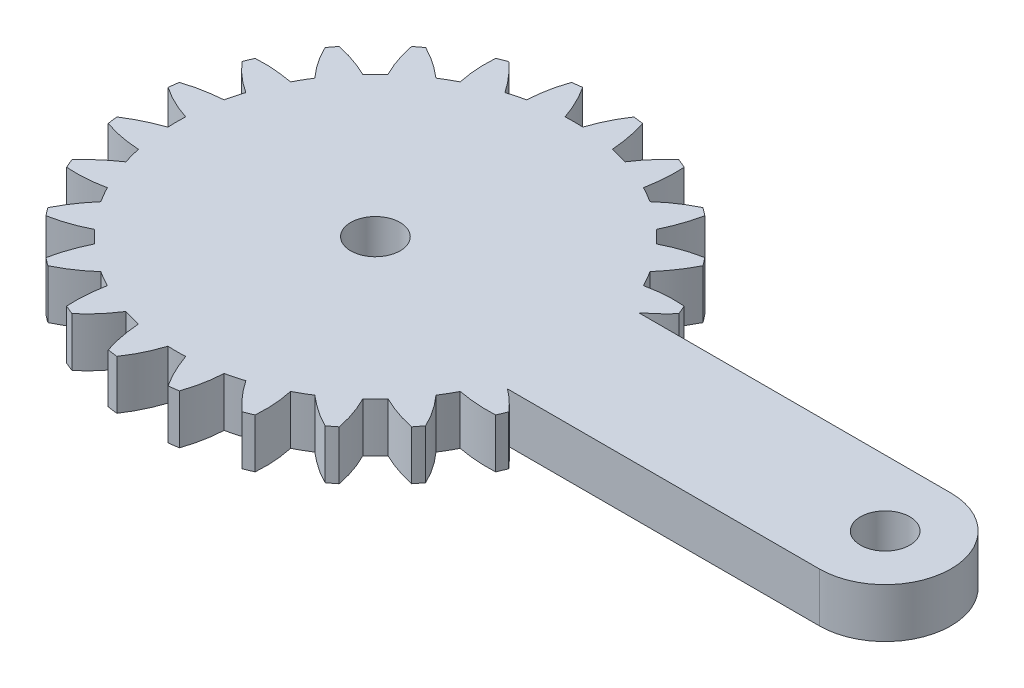
from build123d import *

# Parameters (mm, degrees)
SKETCH2_R           = 1.5
BOSS_EXTRUDE1_DEPTH = 3


with BuildPart() as part:
    # Sketch2 → Boss-Extrude1 (new body)
    with BuildSketch(Plane(origin=(0, 0, 0), x_dir=(1, 0, 0), z_dir=(0, 1, 0))):
        with BuildLine():
            Line((31, 4.000000001), (12.012859152, 4.000000001))
            add(Edge.make_bspline(
                [(13.278985865, 5.170206419), (12.8954662, 4.733530556), (12.462190225, 4.344528056), (12.012859152, 4.000000001)],
                knots=[0.154712813, 0.154712813, 0.154712813, 0.154712813, 0.777489596, 0.777489596, 0.777489596, 0.777489596], degree=3))
            ThreePointArc((13.278985865, 5.170206419), (13.165283338, 5.453238911), (13.045548971, 5.733772933))
            add(Edge.make_bspline(
                [(10.729735914, 5.571433139), (11.468148216, 5.731782959), (12.25282672, 5.797378255), (13.045548971, 5.733772933)],
                knots=[0, 0, 0, 0, 0.84522739, 0.84522739, 0.84522739, 0.84522739], degree=3))
            ThreePointArc((10.729735914, 5.571433139), (10.602635836, 5.809665509), (10.470247132, 6.045))
            ThreePointArc((10.470247132, 6.045), (10.332600838, 6.277376835), (10.189798038, 6.506620931))
            add(Edge.make_bspline(
                [(11.488367505, 8.430890348), (11.138958904, 7.723663869), (10.678280228, 7.077546079), (10.189798038, 6.506620931)],
                knots=[0.154712813, 0.154712813, 0.154712813, 0.154712813, 1, 1, 1, 1], degree=3))
            ThreePointArc((11.488367505, 8.430890348), (11.305285099, 8.674850363), (11.117023034, 8.914835886))
            add(Edge.make_bspline(
                [(8.922136024, 8.158651162), (9.593885949, 8.504652361), (10.334849869, 8.771102293), (11.117023034, 8.914835886)],
                knots=[0, 0, 0, 0, 0.84522739, 0.84522739, 0.84522739, 0.84522739], degree=3))
            ThreePointArc((8.922136024, 8.158651162), (8.737707702, 8.35587004), (8.548920985, 8.548920985))
            ThreePointArc((8.548920985, 8.548920985), (8.355821324, 8.737754288), (8.158551674, 8.922226997))
            add(Edge.make_bspline(
                [(8.914835886, 11.117023034), (8.760376776, 10.343461111), (8.482622935, 9.600126837), (8.158551674, 8.922226997)],
                knots=[0.154712813, 0.154712813, 0.154712813, 0.154712813, 1, 1, 1, 1], degree=3))
            ThreePointArc((8.914835886, 11.117023034), (8.674850363, 11.305285099), (8.430890348, 11.488367505))
            add(Edge.make_bspline(
                [(6.506507308, 10.189870591), (7.065816209, 10.697943759), (7.71257008, 11.147090204), (8.430890348, 11.488367505)],
                knots=[0, 0, 0, 0, 0.84522739, 0.84522739, 0.84522739, 0.84522739], degree=3))
            ThreePointArc((6.506507308, 10.189870591), (6.277319227, 10.332635836), (6.045, 10.470247132))
            ThreePointArc((6.045, 10.470247132), (5.809606396, 10.602668227), (5.571313495, 10.729798038))
            add(Edge.make_bspline(
                [(5.733772933, 13.045548971), (5.784789448, 12.258368573), (5.708888907, 11.468474815), (5.571313495, 10.729798038)],
                knots=[0.154712813, 0.154712813, 0.154712813, 0.154712813, 1, 1, 1, 1], degree=3))
            ThreePointArc((5.733772933, 13.045548971), (5.453238911, 13.165283338), (5.170206419, 13.278985865))
            add(Edge.make_bspline(
                [(3.647470872, 11.526667178), (4.056222772, 12.16218797), (4.564691385, 12.76342234), (5.170206419, 13.278985865)],
                knots=[0, 0, 0, 0, 0.84522739, 0.84522739, 0.84522739, 0.84522739], degree=3))
            ThreePointArc((3.647470872, 11.526667178), (3.389141821, 11.605249576), (3.129122255, 11.67804324))
            ThreePointArc((3.129122255, 11.67804324), (2.867476392, 11.745027848), (2.604399509, 11.806151075))
            add(Edge.make_bspline(
                [(2.161962831, 14.085042304), (2.414978279, 13.337888473), (2.546103534, 12.555265188), (2.604399509, 11.806151075)],
                knots=[0.154712813, 0.154712813, 0.154712813, 0.154712813, 1, 1, 1, 1], degree=3))
            ThreePointArc((2.161962831, 14.085042304), (1.859998239, 14.128089275), (1.557181466, 14.164663282))
            add(Edge.make_bspline(
                [(0.539865323, 12.077940447), (0.770204456, 12.797599169), (1.105736515, 13.509948335), (1.557181466, 14.164663282)],
                knots=[0, 0, 0, 0, 0.84522739, 0.84522739, 0.84522739, 0.84522739], degree=3))
            ThreePointArc((0.539865323, 12.077940447), (0.27, 12.086984736), (0, 12.09))
            ThreePointArc((0, 12.09), (-0.270067389, 12.08698323), (-0.54, 12.077934426))
            add(Edge.make_bspline(
                [(-1.557181466, 14.164663282), (-1.119409669, 13.508453317), (-0.790194587, 12.786434986), (-0.54, 12.077934426)],
                knots=[0.154712813, 0.154712813, 0.154712813, 0.154712813, 1, 1, 1, 1], degree=3))
            ThreePointArc((-1.557181466, 14.164663282), (-1.859998239, 14.128089275), (-2.161962831, 14.085042304))
            add(Edge.make_bspline(
                [(-2.604531155, 11.806122033), (-2.568302021, 12.560875133), (-2.42857247, 13.335793678), (-2.161962831, 14.085042304)],
                knots=[0, 0, 0, 0, 0.84522739, 0.84522739, 0.84522739, 0.84522739], degree=3))
            ThreePointArc((-2.604531155, 11.806122033), (-2.867541874, 11.74501186), (-3.129122255, 11.67804324))
            ThreePointArc((-3.129122255, 11.67804324), (-3.389206524, 11.60523068), (-3.647599401, 11.526626506))
            add(Edge.make_bspline(
                [(-5.170206419, 13.278985865), (-4.577511698, 12.75843939), (-4.072642252, 12.146230371), (-3.647599401, 11.526626506)],
                knots=[0.154712813, 0.154712813, 0.154712813, 0.154712813, 1, 1, 1, 1], degree=3))
            ThreePointArc((-5.170206419, 13.278985865), (-5.453238911, 13.165283338), (-5.733772933, 13.045548971))
            add(Edge.make_bspline(
                [(-5.571433139, 10.729735914), (-5.731782959, 11.468148216), (-5.797378255, 12.25282672), (-5.733772933, 13.045548971)],
                knots=[0, 0, 0, 0, 0.84522739, 0.84522739, 0.84522739, 0.84522739], degree=3))
            ThreePointArc((-5.571433139, 10.729735914), (-5.809665509, 10.602635836), (-6.045, 10.470247132))
            ThreePointArc((-6.045, 10.470247132), (-6.277376835, 10.332600838), (-6.506620931, 10.189798038))
            add(Edge.make_bspline(
                [(-8.430890348, 11.488367505), (-7.723663869, 11.138958904), (-7.077546079, 10.678280228), (-6.506620931, 10.189798038)],
                knots=[0.154712813, 0.154712813, 0.154712813, 0.154712813, 1, 1, 1, 1], degree=3))
            ThreePointArc((-8.430890348, 11.488367505), (-8.674850363, 11.305285099), (-8.914835886, 11.117023034))
            add(Edge.make_bspline(
                [(-8.158651162, 8.922136024), (-8.504652361, 9.593885949), (-8.771102293, 10.334849869), (-8.914835886, 11.117023034)],
                knots=[0, 0, 0, 0, 0.84522739, 0.84522739, 0.84522739, 0.84522739], degree=3))
            ThreePointArc((-8.158651162, 8.922136024), (-8.35587004, 8.737707702), (-8.548920985, 8.548920985))
            ThreePointArc((-8.548920985, 8.548920985), (-8.737754288, 8.355821324), (-8.922226997, 8.158551674))
            add(Edge.make_bspline(
                [(-11.117023034, 8.914835886), (-10.343461111, 8.760376776), (-9.600126837, 8.482622935), (-8.922226997, 8.158551674)],
                knots=[0.154712813, 0.154712813, 0.154712813, 0.154712813, 1, 1, 1, 1], degree=3))
            ThreePointArc((-11.117023034, 8.914835886), (-11.305285099, 8.674850363), (-11.488367505, 8.430890348))
            add(Edge.make_bspline(
                [(-10.189870591, 6.506507308), (-10.697943759, 7.065816209), (-11.147090204, 7.71257008), (-11.488367505, 8.430890348)],
                knots=[0, 0, 0, 0, 0.84522739, 0.84522739, 0.84522739, 0.84522739], degree=3))
            ThreePointArc((-10.189870591, 6.506507308), (-10.332635836, 6.277319227), (-10.470247132, 6.045))
            ThreePointArc((-10.470247132, 6.045), (-10.602668227, 5.809606396), (-10.729798038, 5.571313495))
            add(Edge.make_bspline(
                [(-13.045548971, 5.733772933), (-12.258368573, 5.784789448), (-11.468474815, 5.708888907), (-10.729798038, 5.571313495)],
                knots=[0.154712813, 0.154712813, 0.154712813, 0.154712813, 1, 1, 1, 1], degree=3))
            ThreePointArc((-13.045548971, 5.733772933), (-13.165283338, 5.453238911), (-13.278985865, 5.170206419))
            add(Edge.make_bspline(
                [(-11.526667178, 3.647470872), (-12.16218797, 4.056222772), (-12.76342234, 4.564691385), (-13.278985865, 5.170206419)],
                knots=[0, 0, 0, 0, 0.84522739, 0.84522739, 0.84522739, 0.84522739], degree=3))
            ThreePointArc((-11.526667178, 3.647470872), (-11.605249576, 3.389141821), (-11.67804324, 3.129122255))
            ThreePointArc((-11.67804324, 3.129122255), (-11.745027848, 2.867476392), (-11.806151075, 2.604399509))
            add(Edge.make_bspline(
                [(-14.085042304, 2.161962831), (-13.337888473, 2.414978279), (-12.555265188, 2.546103534), (-11.806151075, 2.604399509)],
                knots=[0.154712813, 0.154712813, 0.154712813, 0.154712813, 1, 1, 1, 1], degree=3))
            ThreePointArc((-14.085042304, 2.161962831), (-14.128089275, 1.859998239), (-14.164663282, 1.557181466))
            add(Edge.make_bspline(
                [(-12.077940447, 0.539865323), (-12.797599169, 0.770204456), (-13.509948335, 1.105736515), (-14.164663282, 1.557181466)],
                knots=[0, 0, 0, 0, 0.84522739, 0.84522739, 0.84522739, 0.84522739], degree=3))
            ThreePointArc((-12.077940447, 0.539865323), (-12.086984736, 0.27), (-12.09, 0))
            ThreePointArc((-12.09, 0), (-12.08698323, -0.270067389), (-12.077934426, -0.54))
            add(Edge.make_bspline(
                [(-14.164663282, -1.557181466), (-13.508453317, -1.119409669), (-12.786434986, -0.790194587), (-12.077934426, -0.54)],
                knots=[0.154712813, 0.154712813, 0.154712813, 0.154712813, 1, 1, 1, 1], degree=3))
            ThreePointArc((-14.164663282, -1.557181466), (-14.128089275, -1.859998239), (-14.085042304, -2.161962831))
            add(Edge.make_bspline(
                [(-11.806122033, -2.604531155), (-12.560875133, -2.568302021), (-13.335793678, -2.42857247), (-14.085042304, -2.161962831)],
                knots=[0, 0, 0, 0, 0.84522739, 0.84522739, 0.84522739, 0.84522739], degree=3))
            ThreePointArc((-11.806122033, -2.604531155), (-11.74501186, -2.867541874), (-11.67804324, -3.129122255))
            ThreePointArc((-11.67804324, -3.129122255), (-11.60523068, -3.389206524), (-11.526626506, -3.647599401))
            add(Edge.make_bspline(
                [(-13.278985865, -5.170206419), (-12.75843939, -4.577511698), (-12.146230371, -4.072642252), (-11.526626506, -3.647599401)],
                knots=[0.154712813, 0.154712813, 0.154712813, 0.154712813, 1, 1, 1, 1], degree=3))
            ThreePointArc((-13.278985865, -5.170206419), (-13.165283338, -5.453238911), (-13.045548971, -5.733772933))
            add(Edge.make_bspline(
                [(-10.729735914, -5.571433139), (-11.468148216, -5.731782959), (-12.25282672, -5.797378255), (-13.045548971, -5.733772933)],
                knots=[0, 0, 0, 0, 0.84522739, 0.84522739, 0.84522739, 0.84522739], degree=3))
            ThreePointArc((-10.729735914, -5.571433139), (-10.602635836, -5.809665509), (-10.470247132, -6.045))
            ThreePointArc((-10.470247132, -6.045), (-10.332600838, -6.277376835), (-10.189798038, -6.506620931))
            add(Edge.make_bspline(
                [(-11.488367505, -8.430890348), (-11.138958904, -7.723663869), (-10.678280228, -7.077546079), (-10.189798038, -6.506620931)],
                knots=[0.154712813, 0.154712813, 0.154712813, 0.154712813, 1, 1, 1, 1], degree=3))
            ThreePointArc((-11.488367505, -8.430890348), (-11.305285099, -8.674850363), (-11.117023034, -8.914835886))
            add(Edge.make_bspline(
                [(-8.922136024, -8.158651162), (-9.593885949, -8.504652361), (-10.334849869, -8.771102293), (-11.117023034, -8.914835886)],
                knots=[0, 0, 0, 0, 0.84522739, 0.84522739, 0.84522739, 0.84522739], degree=3))
            ThreePointArc((-8.922136024, -8.158651162), (-8.737707702, -8.35587004), (-8.548920985, -8.548920985))
            ThreePointArc((-8.548920985, -8.548920985), (-8.355821324, -8.737754288), (-8.158551674, -8.922226997))
            add(Edge.make_bspline(
                [(-8.914835886, -11.117023034), (-8.760376776, -10.343461111), (-8.482622935, -9.600126837), (-8.158551674, -8.922226997)],
                knots=[0.154712813, 0.154712813, 0.154712813, 0.154712813, 1, 1, 1, 1], degree=3))
            ThreePointArc((-8.914835886, -11.117023034), (-8.674850363, -11.305285099), (-8.430890348, -11.488367505))
            add(Edge.make_bspline(
                [(-6.506507308, -10.189870591), (-7.065816209, -10.697943759), (-7.71257008, -11.147090204), (-8.430890348, -11.488367505)],
                knots=[0, 0, 0, 0, 0.84522739, 0.84522739, 0.84522739, 0.84522739], degree=3))
            ThreePointArc((-6.506507308, -10.189870591), (-6.277319227, -10.332635836), (-6.045, -10.470247132))
            ThreePointArc((-6.045, -10.470247132), (-5.809606396, -10.602668227), (-5.571313495, -10.729798038))
            add(Edge.make_bspline(
                [(-5.733772933, -13.045548971), (-5.784789448, -12.258368573), (-5.708888907, -11.468474815), (-5.571313495, -10.729798038)],
                knots=[0.154712813, 0.154712813, 0.154712813, 0.154712813, 1, 1, 1, 1], degree=3))
            ThreePointArc((-5.733772933, -13.045548971), (-5.453238911, -13.165283338), (-5.170206419, -13.278985865))
            add(Edge.make_bspline(
                [(-3.647470872, -11.526667178), (-4.056222772, -12.16218797), (-4.564691385, -12.76342234), (-5.170206419, -13.278985865)],
                knots=[0, 0, 0, 0, 0.84522739, 0.84522739, 0.84522739, 0.84522739], degree=3))
            ThreePointArc((-3.647470872, -11.526667178), (-3.389141821, -11.605249576), (-3.129122255, -11.67804324))
            ThreePointArc((-3.129122255, -11.67804324), (-2.867476392, -11.745027848), (-2.604399509, -11.806151075))
            add(Edge.make_bspline(
                [(-2.161962831, -14.085042304), (-2.414978279, -13.337888473), (-2.546103534, -12.555265188), (-2.604399509, -11.806151075)],
                knots=[0.154712813, 0.154712813, 0.154712813, 0.154712813, 1, 1, 1, 1], degree=3))
            ThreePointArc((-2.161962831, -14.085042304), (-1.859998239, -14.128089275), (-1.557181466, -14.164663282))
            add(Edge.make_bspline(
                [(-0.539865323, -12.077940447), (-0.770204456, -12.797599169), (-1.105736515, -13.509948335), (-1.557181466, -14.164663282)],
                knots=[0, 0, 0, 0, 0.84522739, 0.84522739, 0.84522739, 0.84522739], degree=3))
            ThreePointArc((-0.539865323, -12.077940447), (-0.27, -12.086984736), (0, -12.09))
            ThreePointArc((0, -12.09), (0.270067389, -12.08698323), (0.54, -12.077934426))
            add(Edge.make_bspline(
                [(1.557181466, -14.164663282), (1.119409669, -13.508453317), (0.790194587, -12.786434986), (0.54, -12.077934426)],
                knots=[0.154712813, 0.154712813, 0.154712813, 0.154712813, 1, 1, 1, 1], degree=3))
            ThreePointArc((1.557181466, -14.164663282), (1.859998239, -14.128089275), (2.161962831, -14.085042304))
            add(Edge.make_bspline(
                [(2.604531155, -11.806122033), (2.568302021, -12.560875133), (2.42857247, -13.335793678), (2.161962831, -14.085042304)],
                knots=[0, 0, 0, 0, 0.84522739, 0.84522739, 0.84522739, 0.84522739], degree=3))
            ThreePointArc((2.604531155, -11.806122033), (2.867541874, -11.74501186), (3.129122255, -11.67804324))
            ThreePointArc((3.129122255, -11.67804324), (3.389206524, -11.60523068), (3.647599401, -11.526626506))
            add(Edge.make_bspline(
                [(5.170206419, -13.278985865), (4.577511698, -12.75843939), (4.072642252, -12.146230371), (3.647599401, -11.526626506)],
                knots=[0.154712813, 0.154712813, 0.154712813, 0.154712813, 1, 1, 1, 1], degree=3))
            ThreePointArc((5.170206419, -13.278985865), (5.453238911, -13.165283338), (5.733772933, -13.045548971))
            add(Edge.make_bspline(
                [(5.571433139, -10.729735914), (5.731782959, -11.468148216), (5.797378255, -12.25282672), (5.733772933, -13.045548971)],
                knots=[0, 0, 0, 0, 0.84522739, 0.84522739, 0.84522739, 0.84522739], degree=3))
            ThreePointArc((5.571433139, -10.729735914), (5.809665509, -10.602635836), (6.045, -10.470247132))
            ThreePointArc((6.045, -10.470247132), (6.277376835, -10.332600838), (6.506620931, -10.189798038))
            add(Edge.make_bspline(
                [(8.430890348, -11.488367505), (7.723663869, -11.138958904), (7.077546079, -10.678280228), (6.506620931, -10.189798038)],
                knots=[0.154712813, 0.154712813, 0.154712813, 0.154712813, 1, 1, 1, 1], degree=3))
            ThreePointArc((8.430890348, -11.488367505), (8.674850363, -11.305285099), (8.914835886, -11.117023034))
            add(Edge.make_bspline(
                [(8.158651162, -8.922136024), (8.504652361, -9.593885949), (8.771102293, -10.334849869), (8.914835886, -11.117023034)],
                knots=[0, 0, 0, 0, 0.84522739, 0.84522739, 0.84522739, 0.84522739], degree=3))
            ThreePointArc((8.158651162, -8.922136024), (8.35587004, -8.737707702), (8.548920985, -8.548920985))
            ThreePointArc((8.548920985, -8.548920985), (8.737754288, -8.355821324), (8.922226997, -8.158551674))
            add(Edge.make_bspline(
                [(11.117023034, -8.914835886), (10.343461111, -8.760376776), (9.600126837, -8.482622935), (8.922226997, -8.158551674)],
                knots=[0.154712813, 0.154712813, 0.154712813, 0.154712813, 1, 1, 1, 1], degree=3))
            ThreePointArc((11.117023034, -8.914835886), (11.305285099, -8.674850363), (11.488367505, -8.430890348))
            add(Edge.make_bspline(
                [(10.189870591, -6.506507308), (10.697943759, -7.065816209), (11.147090204, -7.71257008), (11.488367505, -8.430890348)],
                knots=[0, 0, 0, 0, 0.84522739, 0.84522739, 0.84522739, 0.84522739], degree=3))
            ThreePointArc((10.189870591, -6.506507308), (10.332635836, -6.277319227), (10.470247132, -6.045))
            ThreePointArc((10.470247132, -6.045), (10.602668227, -5.809606396), (10.729798038, -5.571313495))
            add(Edge.make_bspline(
                [(13.045548971, -5.733772933), (12.258368573, -5.784789448), (11.468474815, -5.708888907), (10.729798038, -5.571313495)],
                knots=[0.154712813, 0.154712813, 0.154712813, 0.154712813, 1, 1, 1, 1], degree=3))
            ThreePointArc((13.045548971, -5.733772933), (13.165283338, -5.453238911), (13.278985865, -5.170206419))
            add(Edge.make_bspline(
                [(12.032510858, -3.999999999), (12.480346232, -4.337627374), (12.902507267, -4.728042767), (13.278985865, -5.170206419)],
                knots=[0.228019214, 0.228019214, 0.228019214, 0.228019214, 0.84522739, 0.84522739, 0.84522739, 0.84522739], degree=3))
            Line((12.032510858, -3.999999999), (31, -3.999999999))
            ThreePointArc((31, -3.999999999), (35, 1e-09), (31, 4.000000001))
        make_face()
        with Locations((31, 1e-09)):
            Circle(SKETCH2_R, mode=Mode.SUBTRACT)
        Circle(SKETCH2_R, mode=Mode.SUBTRACT)
    extrude(amount=BOSS_EXTRUDE1_DEPTH)


solid = part.part
